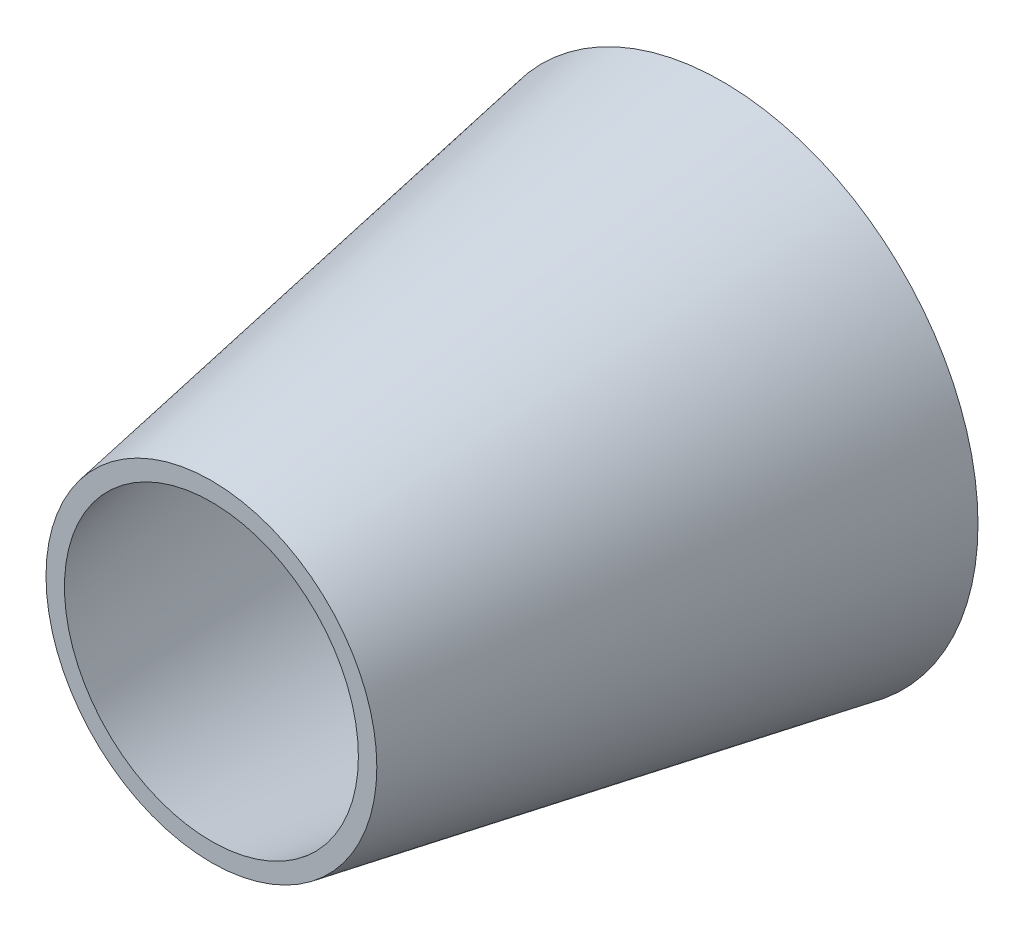
from build123d import *

# Parameters (mm, degrees)
SKETCH2_R           = 15
BOSS_EXTRUDE1_DEPTH = 30
BOSS_EXTRUDE1_TAPER = 10
SKETCH3_R           = 8.628165901
CUT_EXTRUDE1_DEPTH  = 30
CUT_EXTRUDE1_TAPER  = -9


with BuildPart() as part:
    # Sketch2 → Boss-Extrude1 (new body)
    with BuildSketch(Plane.XY):
        Circle(SKETCH2_R)
    extrude(amount=BOSS_EXTRUDE1_DEPTH, taper=BOSS_EXTRUDE1_TAPER)

    # Sketch3 → Cut-Extrude1 (cut)
    with BuildSketch(Plane.XY.offset(30)):
        Circle(SKETCH3_R)
    extrude(amount=-CUT_EXTRUDE1_DEPTH, taper=CUT_EXTRUDE1_TAPER, mode=Mode.SUBTRACT)


solid = part.part
